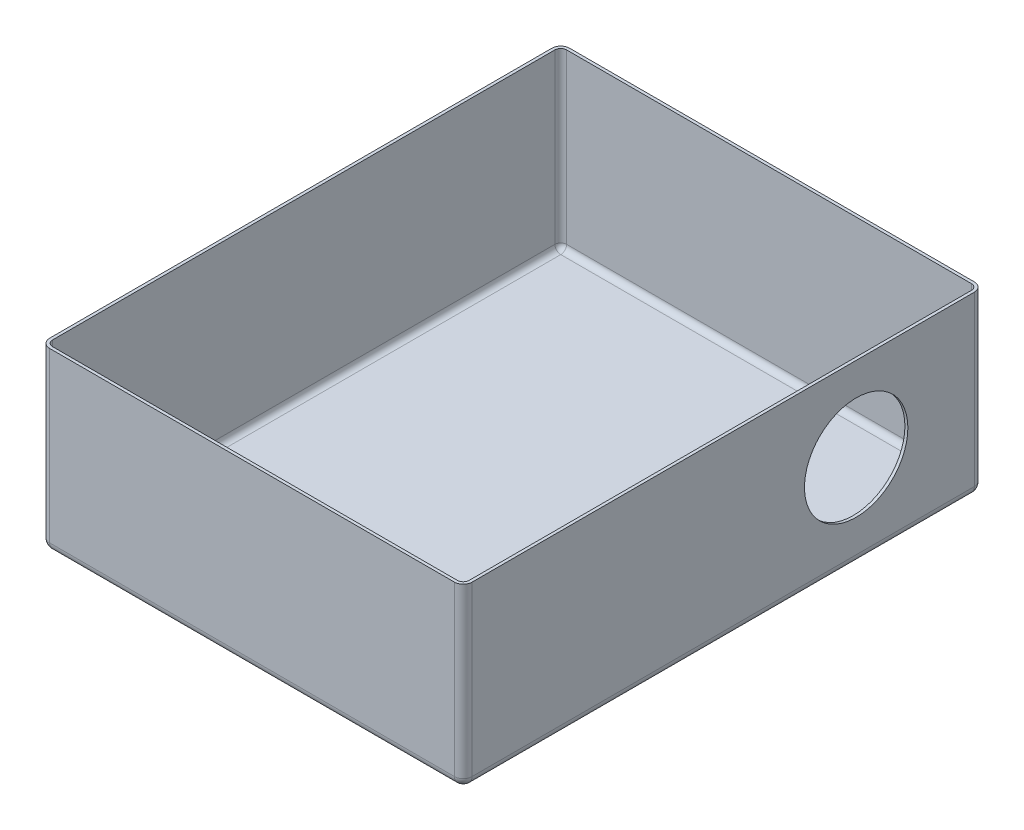
from build123d import *

# Parameters (mm, degrees)
SKETCH1_W           = 143
SKETCH1_H           = 176
BOSS_EXTRUDE1_DEPTH = 60
FILLET1_R           = 3
FILLET2_R           = 3
SHELL1_T            = -1
SKETCH2_R           = 17.5
CUT_EXTRUDE1_DEPTH  = 60


with BuildPart() as part:
    # Sketch1 → Boss-Extrude1 (new body)
    with BuildSketch(Plane(origin=(0, 0, 0), x_dir=(1, 0, 0), z_dir=(0, 1, 0))):
        Rectangle(SKETCH1_W, SKETCH1_H)
    extrude(amount=BOSS_EXTRUDE1_DEPTH)

    # Fillet1
    fillet1_edges = [part.edges().sort_by_distance(p)[0] for p in [
        (71.5, 30, 88),
        (-71.5, 30, 88),
        (-71.5, 30, -88),
        (71.5, 30, -88),
    ]]
    fillet(fillet1_edges, radius=FILLET1_R)

    # Fillet2
    fillet2_edges = [part.edges().sort_by_distance(p)[0] for p in [
        (0, 0, 88),
        (71.5, 0, 0),
        (-71.5, 0, 0),
        (0, 0, -88),
        (-70.621320344, 0, -87.121320344),
        (70.621320344, 0, -87.121320344),
        (70.621320344, 0, 87.121320344),
        (-70.621320344, 0, 87.121320344),
    ]]
    fillet(fillet2_edges, radius=FILLET2_R)

    # Shell1
    shell1_openings = [part.faces().sort_by_distance(p)[0] for p in [
        (0, 60, 0),
    ]]
    offset(amount=SHELL1_T, openings=shell1_openings, kind=Kind.INTERSECTION)

    # Sketch2 → Cut-Extrude1 (cut)
    with BuildSketch(Plane(origin=(71.5, 0, 0), x_dir=(0, 0, -1), z_dir=(1, 0, 0))):
        with Locations((45, 31.5)):
            Circle(SKETCH2_R)
    extrude(amount=-CUT_EXTRUDE1_DEPTH, mode=Mode.SUBTRACT)


solid = part.part
